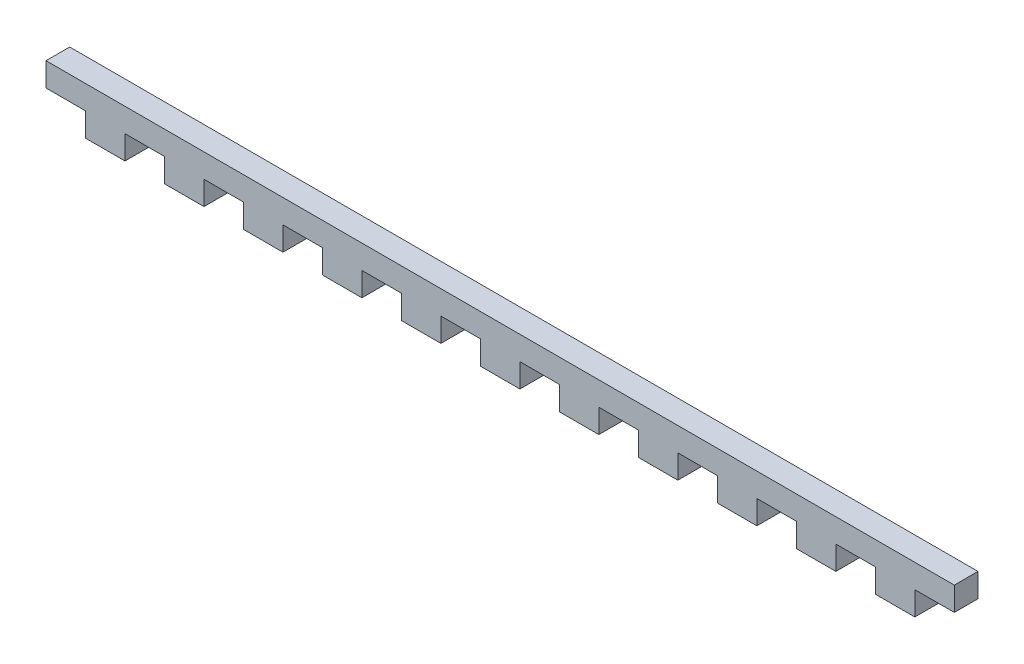
from build123d import *

# Parameters (mm, degrees)
BOSS_EXTRU_1_DEPTH = 3


with BuildPart() as part:
    # Esquisse1 → Boss.-Extru.1 (new body)
    with BuildSketch(Plane.XY):
        Polygon((18.990106642, -2.899569673), (18.990106642, 0.100430327), (23.990106642, 0.100430327), (23.990106642, -2.899569673), (28.990106642, -2.899569673), (28.990106642, 0.100430327), (33.990106642, 0.100430327), (33.990106642, -2.899569673), (38.990106642, -2.899569673), (38.990106642, 0.100430327), (43.990106642, 0.100430327), (43.990106642, -2.899569673), (48.990106642, -2.899569673), (48.990106642, 0.100430327), (53.990106642, 0.100430327), (53.990106642, -2.899569673), (58.990106642, -2.899569673), (58.990106642, 0.100430327), (63.990106642, 0.100430327), (63.990106642, -2.899569673), (68.990106642, -2.899569673), (68.990106642, 0.100430327), (73.990106642, 0.100430327), (73.990106642, -2.899569673), (78.990106642, -2.899569673), (78.990106642, 0.100430327), (83.990106642, 0.100430327), (83.990106642, -2.899569673), (88.990106642, -2.899569673), (88.990106642, 0.100430327), (93.990106642, 0.100430327), (93.990106642, -2.899569673), (98.990106642, -2.899569673), (98.990106642, 0.100430327), (103.990106642, 0.100430327), (103.990106642, -2.899569673), (108.990106642, -2.899569673), (108.990106642, 0.100430327), (113.990106642, 0.100430327), (113.990106642, 3.100430327), (-1.009893358, 3.100430327), (-1.009893358, 0.100430327), (3.990106642, 0.100430327), (3.990106642, -2.899569673), (8.990106642, -2.899569673), (8.990106642, 0.100430327), (13.990106642, 0.100430327), (13.990106642, -2.899569673), align=None)
    extrude(amount=BOSS_EXTRU_1_DEPTH)


solid = part.part
